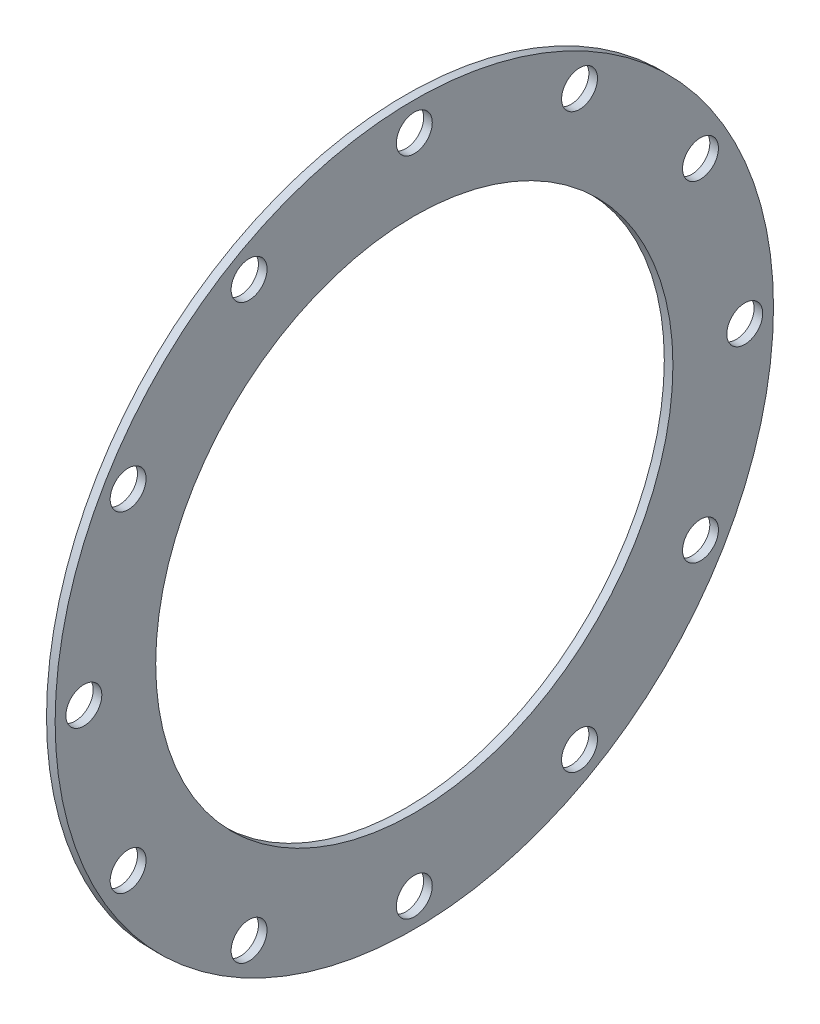
from build123d import *

# Parameters (mm, degrees)
SKETCH1_R           = 2500
SKETCH1_R_2         = 125
BOSS_EXTRUDE1_DEPTH = 60
SKETCH3_R           = 1800
CUT_EXTRUDE1_DEPTH  = 60


with BuildPart() as part:
    # Sketch1 → Boss-Extrude1 (new body)
    with BuildSketch(Plane(origin=(0, 0, 0), x_dir=(0, 0, -1), z_dir=(1, 0, 0))):
        Circle(SKETCH1_R)
        with Locations((0, 2300)):
            Circle(SKETCH1_R_2, mode=Mode.SUBTRACT)
        with Locations((1150, 1991.858428704)):
            Circle(SKETCH1_R_2, mode=Mode.SUBTRACT)
        with Locations((1991.858428704, 1150)):
            Circle(SKETCH1_R_2, mode=Mode.SUBTRACT)
        with Locations((2300, 0)):
            Circle(SKETCH1_R_2, mode=Mode.SUBTRACT)
        with Locations((1991.858428704, -1150)):
            Circle(SKETCH1_R_2, mode=Mode.SUBTRACT)
        with Locations((1150, -1991.858428704)):
            Circle(SKETCH1_R_2, mode=Mode.SUBTRACT)
        with Locations((0, -2300)):
            Circle(SKETCH1_R_2, mode=Mode.SUBTRACT)
        with Locations((-1150, -1991.858428704)):
            Circle(SKETCH1_R_2, mode=Mode.SUBTRACT)
        with Locations((-1991.858428704, -1150)):
            Circle(SKETCH1_R_2, mode=Mode.SUBTRACT)
        with Locations((-2300, 0)):
            Circle(SKETCH1_R_2, mode=Mode.SUBTRACT)
        with Locations((-1991.858428704, 1150)):
            Circle(SKETCH1_R_2, mode=Mode.SUBTRACT)
        with Locations((-1150, 1991.858428704)):
            Circle(SKETCH1_R_2, mode=Mode.SUBTRACT)
    extrude(amount=BOSS_EXTRUDE1_DEPTH)

    # Sketch3 → Cut-Extrude1 (cut)
    with BuildSketch(Plane(origin=(60, 0, 0), x_dir=(0, 0, -1), z_dir=(1, 0, 0))):
        Circle(SKETCH3_R)
    extrude(amount=-CUT_EXTRUDE1_DEPTH, mode=Mode.SUBTRACT)


solid = part.part
